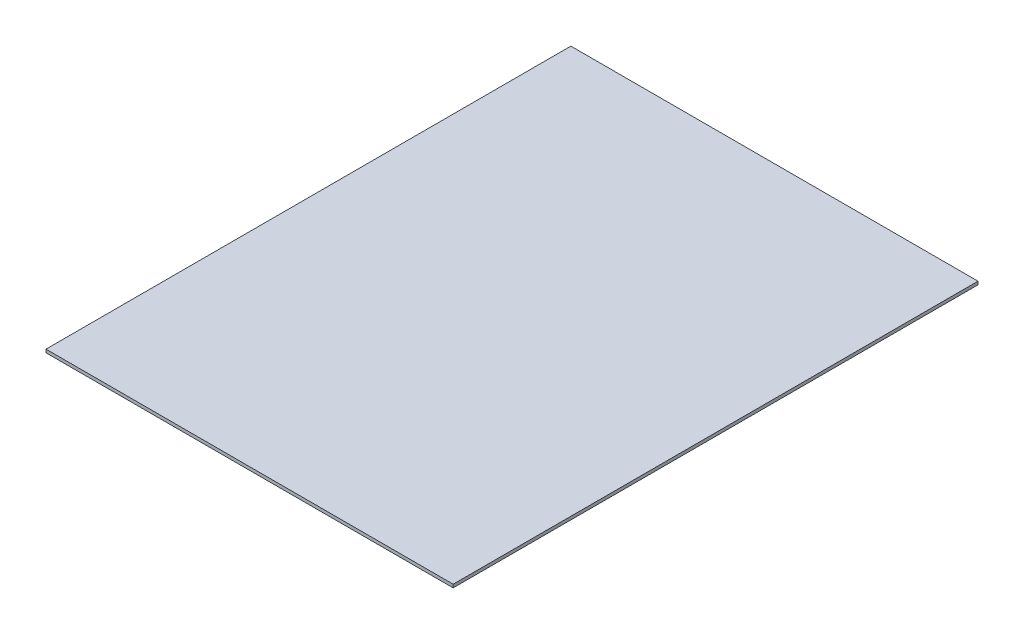
from build123d import *

# Parameters (mm, degrees)
SKETCH1_W           = 1280
SKETCH1_H           = 1650
BOSS_EXTRUDE1_DEPTH = 10


with BuildPart() as part:
    # Sketch1 → Boss-Extrude1 (new body)
    with BuildSketch(Plane(origin=(0, 0, 0), x_dir=(1, 0, 0), z_dir=(0, 1, 0))):
        with Locations((-26.99751861, -178.64764268)):
            Rectangle(SKETCH1_W, SKETCH1_H)
    extrude(amount=BOSS_EXTRUDE1_DEPTH)


solid = part.part
